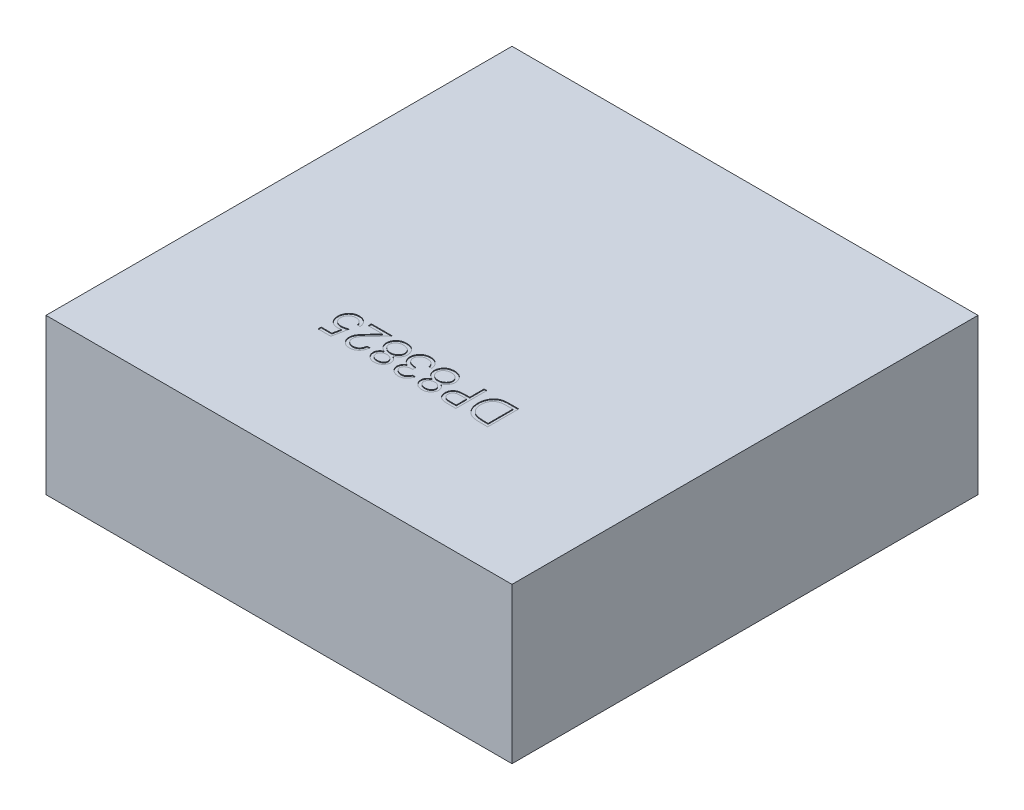
from build123d import *

# Parameters (mm, degrees)
BASES_W          = 3
BASES_H          = 3
BASE_DEPTH       = 1
PARTNUMBER_DEPTH = 0.005


with BuildPart() as part:
    # BaseS → Base (new body)
    with BuildSketch(Plane(origin=(0, 0, 0), x_dir=(1, 0, 0), z_dir=(0, 1, 0))):
        Rectangle(BASES_W, BASES_H)
    extrude(amount=BASE_DEPTH)

    # PartNumberS → PartNumber (cut)
    with BuildSketch(Plane(origin=(0, 1, 0), x_dir=(1, 0, 0), z_dir=(0, 1, 0))):
        with BuildLine():
            Line((0.543589744, -0.5), (0.543589744, -0.7))
            Line((0.543589744, -0.7), (0.503205128, -0.7))
            add(Edge.make_bspline(
                [(0.503205128, -0.7), (0.499692607, -0.699974779), (0.492906435, -0.699926053), (0.483100107, -0.699615336), (0.474039691, -0.699071227), (0.46573033, -0.698263381), (0.458158677, -0.697293739), (0.451336857, -0.696060596), (0.445253815, -0.694610337), (0.441512712, -0.693373396), (0.43974359, -0.692788462)],
                knots=[0, 0, 0, 0, 1.314317071, 2.539253741, 3.67075822, 4.709970291, 5.662644612, 6.526156501, 7.303037452, 8, 8, 8, 8], degree=3))
            add(Edge.make_bspline(
                [(0.43974359, -0.692788462), (0.437429398, -0.691906981), (0.432853492, -0.690164008), (0.426341803, -0.686871104), (0.420190986, -0.683155356), (0.414449607, -0.678931575), (0.409105016, -0.674253735), (0.404089966, -0.669159683), (0.399548204, -0.663513427), (0.395323083, -0.657490166), (0.391625007, -0.651035088), (0.388364014, -0.644277488), (0.385579621, -0.637230477), (0.383407047, -0.629842637), (0.381612125, -0.622184924), (0.380407776, -0.614199361), (0.379607776, -0.605932503), (0.379527773, -0.600322461), (0.379487179, -0.597475962)],
                knots=[0, 0, 0, 0, 0.984696416, 1.947063185, 2.89840987, 3.841051395, 4.778753227, 5.721858861, 6.681155121, 7.65838316, 8.646299769, 9.637283673, 10.641736726, 11.657050558, 12.698485921, 13.768600492, 14.86780186, 16, 16, 16, 16], degree=3))
            add(Edge.make_bspline(
                [(0.379487179, -0.597475962), (0.379523145, -0.595003899), (0.379594018, -0.590132442), (0.380229632, -0.582952842), (0.381155261, -0.575986791), (0.382581759, -0.569264875), (0.384334606, -0.562741838), (0.386498066, -0.556448566), (0.389062316, -0.550380781), (0.392036117, -0.544586677), (0.395292309, -0.539080345), (0.398840463, -0.533949028), (0.402559095, -0.529136152), (0.40658383, -0.524750444), (0.410781412, -0.520655332), (0.415294606, -0.517032476), (0.419982101, -0.513713686), (0.424984721, -0.510799747), (0.430343511, -0.508207712), (0.436198451, -0.506018723), (0.442528171, -0.504134935), (0.449374613, -0.502634061), (0.456714945, -0.501424281), (0.464569063, -0.500618629), (0.472922261, -0.500072297), (0.478658238, -0.500024567), (0.481610577, -0.5)],
                knots=[0, 0, 0, 0, 1.105894396, 2.179280415, 3.222964075, 4.248423888, 5.251546139, 6.243661943, 7.223682738, 8.196462441, 9.155694589, 10.083899862, 10.986397372, 11.874737962, 12.745335529, 13.607670254, 14.461432187, 15.313100333, 16.195087267, 17.121790994, 18.106827133, 19.14775296, 20.255889161, 21.433815148, 22.679170477, 24, 24, 24, 24], degree=3))
            Line((0.481610577, -0.5), (0.543589744, -0.5))
        make_face()
        with BuildLine():
            Line((0.525641026, -0.520512821), (0.502684295, -0.520512821))
            add(Edge.make_bspline(
                [(0.502684295, -0.520512821), (0.499385531, -0.520526997), (0.493040799, -0.520554265), (0.483917485, -0.520793534), (0.47558152, -0.521184501), (0.468031719, -0.521731649), (0.461272346, -0.52245557), (0.455289275, -0.523262707), (0.450102117, -0.524268276), (0.446963292, -0.525179759), (0.445512821, -0.525600962)],
                knots=[0, 0, 0, 0, 1.375205317, 2.645023457, 3.804390687, 4.853969522, 5.800190428, 6.637939096, 7.370582563, 8, 8, 8, 8], degree=3))
            add(Edge.make_bspline(
                [(0.445512821, -0.525600962), (0.443687161, -0.52624386), (0.440079448, -0.5275143), (0.434886804, -0.529832576), (0.430041477, -0.532575274), (0.42546269, -0.535641994), (0.42117987, -0.539080089), (0.41721285, -0.542900492), (0.413530295, -0.547058974), (0.410191167, -0.551569547), (0.407171191, -0.556382165), (0.404561941, -0.561491465), (0.402362373, -0.566868777), (0.400557774, -0.572495393), (0.399150806, -0.57837466), (0.398160244, -0.584521333), (0.397546405, -0.590932984), (0.397473135, -0.595297753), (0.397435897, -0.597516026)],
                knots=[0, 0, 0, 0, 0.998420628, 1.972994, 2.929372424, 3.86770908, 4.81360496, 5.759023883, 6.706048443, 7.676227424, 8.651287839, 9.634325482, 10.632389399, 11.645655052, 12.680158286, 13.74837235, 14.855672678, 16, 16, 16, 16], degree=3))
            add(Edge.make_bspline(
                [(0.397435897, -0.597516026), (0.397465259, -0.599855068), (0.397522941, -0.604450136), (0.398246744, -0.61119266), (0.399306725, -0.61767655), (0.400831424, -0.623906472), (0.402801204, -0.629874323), (0.405158205, -0.635613817), (0.408019974, -0.641051094), (0.4112598, -0.646232204), (0.414897097, -0.651078684), (0.418915732, -0.655533753), (0.423273329, -0.659605711), (0.427949807, -0.663301041), (0.43301055, -0.666554027), (0.438369921, -0.669447832), (0.444103412, -0.671906581), (0.448092784, -0.673213849), (0.450120192, -0.673878205)],
                knots=[0, 0, 0, 0, 1.122272916, 2.204715076, 3.251197285, 4.274229216, 5.279697671, 6.265416158, 7.248880903, 8.225321784, 9.195852973, 10.153576302, 11.101466393, 12.055578741, 13.010401466, 13.985536859, 14.976245305, 16, 16, 16, 16], degree=3))
            add(Edge.make_bspline(
                [(0.450120192, -0.673878205), (0.451797401, -0.674342001), (0.455363606, -0.675328158), (0.461183004, -0.676403894), (0.467732441, -0.677352722), (0.475040995, -0.678156039), (0.483100336, -0.678732457), (0.491916661, -0.679165104), (0.501493781, -0.679456911), (0.508132783, -0.679476838), (0.511578526, -0.679487179)],
                knots=[0, 0, 0, 0, 0.674548936, 1.434276114, 2.292660221, 3.240891867, 4.284742987, 5.42552168, 6.663806718, 8, 8, 8, 8], degree=3))
            Line((0.511578526, -0.679487179), (0.525641026, -0.679487179))
            Line((0.525641026, -0.679487179), (0.525641026, -0.520512821))
        make_face(mode=Mode.SUBTRACT)
        with BuildLine():
            Line((0.338461538, -0.7), (0.299238782, -0.7))
            add(Edge.make_bspline(
                [(0.299238782, -0.7), (0.296541016, -0.699997035), (0.291371976, -0.699991352), (0.283959687, -0.699819081), (0.277227703, -0.699588985), (0.271190538, -0.699270019), (0.265829618, -0.698893071), (0.261169201, -0.698364383), (0.257172655, -0.697812366), (0.254778001, -0.697251143), (0.253685897, -0.696995192)],
                knots=[0, 0, 0, 0, 1.415646017, 2.712440637, 3.8905458, 4.950247383, 5.884950622, 6.709939814, 7.411656543, 8, 8, 8, 8], degree=3))
            add(Edge.make_bspline(
                [(0.253685897, -0.696995192), (0.252303419, -0.696616784), (0.249571037, -0.695868883), (0.245633708, -0.694371122), (0.241888245, -0.692594385), (0.238318984, -0.690572427), (0.234987068, -0.688209761), (0.231788469, -0.685642753), (0.228790266, -0.682767587), (0.226037732, -0.679588048), (0.22348739, -0.676208296), (0.221352571, -0.67254215), (0.219467441, -0.66871679), (0.217998343, -0.664638818), (0.216843575, -0.660362064), (0.216002557, -0.655875395), (0.215462016, -0.651188492), (0.215410725, -0.64798496), (0.215384615, -0.646354167)],
                knots=[0, 0, 0, 0, 0.999333726, 1.975119402, 2.933498163, 3.889020618, 4.832249799, 5.779334906, 6.747801194, 7.724875447, 8.710438469, 9.696133548, 10.679360639, 11.681339199, 12.714023775, 13.766351759, 14.862936069, 16, 16, 16, 16], degree=3))
            add(Edge.make_bspline(
                [(0.215384615, -0.646354167), (0.215408697, -0.644709722), (0.215455814, -0.641492256), (0.216021316, -0.636785239), (0.216783041, -0.632287046), (0.217954301, -0.628007648), (0.21948834, -0.623972462), (0.221287885, -0.62011982), (0.223458373, -0.616515267), (0.225952363, -0.613145717), (0.22872674, -0.610008008), (0.231769765, -0.607124877), (0.235069153, -0.604513201), (0.238614419, -0.602167124), (0.242440124, -0.600141051), (0.246488247, -0.598326348), (0.250793974, -0.596802287), (0.253773546, -0.596000569), (0.255288462, -0.595592949)],
                knots=[0, 0, 0, 0, 1.121902311, 2.195077645, 3.232258892, 4.234102512, 5.217864754, 6.176164875, 7.132989551, 8.084763148, 9.034132444, 9.988522005, 10.94243251, 11.903244335, 12.886203696, 13.894208494, 14.929344452, 16, 16, 16, 16], degree=3))
            add(Edge.make_bspline(
                [(0.255288462, -0.595592949), (0.256541466, -0.595326691), (0.259287499, -0.594743172), (0.263809657, -0.594087314), (0.269077464, -0.593549438), (0.275072997, -0.593047488), (0.281810237, -0.592781517), (0.289273732, -0.592469224), (0.297488742, -0.59232187), (0.303218455, -0.592312555), (0.306209936, -0.592307692)],
                knots=[0, 0, 0, 0, 0.601372724, 1.317943291, 2.144091499, 3.08771165, 4.142394186, 5.309582461, 6.595334295, 8, 8, 8, 8], degree=3))
            Line((0.306209936, -0.592307692), (0.320512821, -0.592307692))
            Line((0.320512821, -0.592307692), (0.320512821, -0.5))
            Line((0.320512821, -0.5), (0.338461538, -0.5))
            Line((0.338461538, -0.5), (0.338461538, -0.7))
        make_face()
        with BuildLine():
            Line((0.320512821, -0.679487179), (0.320512821, -0.612820513))
            Line((0.320512821, -0.612820513), (0.285496795, -0.612379808))
            add(Edge.make_bspline(
                [(0.285496795, -0.612379808), (0.283787056, -0.61237868), (0.28048644, -0.612376504), (0.275705726, -0.612608136), (0.271281004, -0.612860126), (0.267205742, -0.613267653), (0.26349854, -0.613764708), (0.260150423, -0.614429274), (0.25713467, -0.615107089), (0.253660857, -0.616283217), (0.249769822, -0.618057557), (0.245546671, -0.620707753), (0.241938335, -0.624046335), (0.238842209, -0.627840667), (0.236394934, -0.632066148), (0.234621287, -0.636574615), (0.233538689, -0.641348947), (0.233402616, -0.644612418), (0.233333333, -0.646274038)],
                knots=[0, 0, 0, 0, 1.160501667, 2.240324542, 3.248665471, 4.168823117, 5.020172044, 5.786515869, 6.485785279, 7.116517804, 8.272762037, 9.381837012, 10.485674779, 11.594342068, 12.695271952, 13.786226926, 14.872841088, 16, 16, 16, 16], degree=3))
            add(Edge.make_bspline(
                [(0.233333333, -0.646274038), (0.233405707, -0.647881827), (0.233549577, -0.651077912), (0.234612344, -0.655764279), (0.236413717, -0.660221491), (0.238844205, -0.664413482), (0.241866136, -0.668197729), (0.24540271, -0.671461906), (0.249398902, -0.674103874), (0.253087222, -0.675862608), (0.256387977, -0.676893968), (0.25924118, -0.677638558), (0.262479129, -0.678152086), (0.26607118, -0.678643436), (0.270012736, -0.679040062), (0.274328858, -0.679315492), (0.279005171, -0.679474996), (0.282251474, -0.67948302), (0.283934295, -0.679487179)],
                knots=[0, 0, 0, 0, 1.12039168, 2.227199994, 3.330242575, 4.460839274, 5.593542475, 6.693949254, 7.801736126, 8.92216649, 9.528704869, 10.210659466, 10.975987387, 11.81211542, 12.738540127, 13.736887663, 14.826846554, 16, 16, 16, 16], degree=3))
            Line((0.283934295, -0.679487179), (0.320512821, -0.679487179))
        make_face(mode=Mode.SUBTRACT)
        with BuildLine():
            add(Edge.make_bspline(
                [(0.095072115, -0.611418269), (0.093448086, -0.610564826), (0.09027078, -0.60889512), (0.085744586, -0.606198493), (0.081520102, -0.60345477), (0.077675464, -0.600565302), (0.074172977, -0.597591509), (0.071001864, -0.594541261), (0.068128021, -0.591424203), (0.065650177, -0.588160203), (0.063451692, -0.584807304), (0.061589306, -0.581324182), (0.059963915, -0.577761169), (0.058688187, -0.574064171), (0.057634926, -0.570283906), (0.056910765, -0.566369649), (0.056521184, -0.56234771), (0.056447543, -0.559629518), (0.056410256, -0.558253205)],
                knots=[0, 0, 0, 0, 1.264219729, 2.473363326, 3.62979159, 4.734286947, 5.785533755, 6.79450939, 7.765315851, 8.704182021, 9.615576613, 10.525715488, 11.423813905, 12.311666436, 13.218214638, 14.126256791, 15.051260205, 16, 16, 16, 16], degree=3))
            add(Edge.make_bspline(
                [(0.056410256, -0.558253205), (0.056454091, -0.556327537), (0.056540855, -0.552515919), (0.057304446, -0.546891633), (0.058432371, -0.54140719), (0.060145798, -0.536124764), (0.06225425, -0.530999346), (0.064914839, -0.52609999), (0.067917657, -0.521286058), (0.070332554, -0.518325141), (0.071554487, -0.516826923)],
                knots=[0, 0, 0, 0, 1.02531512, 2.029483338, 3.018748588, 4.004195107, 4.983200899, 5.966616707, 6.971112471, 8, 8, 8, 8], degree=3))
            add(Edge.make_bspline(
                [(0.071554487, -0.516826923), (0.073145143, -0.515078707), (0.076306798, -0.511603879), (0.081722965, -0.507092404), (0.087667073, -0.50330101), (0.094116121, -0.500211188), (0.101052869, -0.497806282), (0.108475841, -0.496078138), (0.116399507, -0.495088285), (0.121845534, -0.4949452), (0.124639423, -0.494871795)],
                knots=[0, 0, 0, 0, 0.954267603, 1.896743057, 2.838368354, 3.796610408, 4.779680527, 5.799409237, 6.871065594, 8, 8, 8, 8], degree=3))
            add(Edge.make_bspline(
                [(0.124639423, -0.494871795), (0.127325841, -0.494937827), (0.132553336, -0.49506632), (0.140163209, -0.49593214), (0.147265419, -0.497464973), (0.153893637, -0.499519585), (0.159983771, -0.502259459), (0.165546895, -0.505617745), (0.170664546, -0.509518623), (0.175176177, -0.514055973), (0.179180498, -0.518916859), (0.182701081, -0.523930136), (0.185610833, -0.529092156), (0.188118805, -0.534324398), (0.189985223, -0.539732879), (0.19130901, -0.545262095), (0.192140532, -0.550896339), (0.192251744, -0.554698039), (0.192307692, -0.556610577)],
                knots=[0, 0, 0, 0, 1.256864279, 2.445730223, 3.576845088, 4.651810441, 5.686528262, 6.692706664, 7.686234615, 8.689148594, 9.678739427, 10.630299996, 11.55097961, 12.448208961, 13.341360817, 14.221834469, 15.105450545, 16, 16, 16, 16], degree=3))
            add(Edge.make_bspline(
                [(0.192307692, -0.556610577), (0.192274662, -0.558013956), (0.192209384, -0.560787529), (0.191757795, -0.56488525), (0.191031164, -0.568873432), (0.190046512, -0.572767815), (0.188699829, -0.57654785), (0.187102182, -0.580233033), (0.185221368, -0.583823256), (0.182983326, -0.587263859), (0.180517583, -0.590676716), (0.177590521, -0.593892364), (0.174397283, -0.597099685), (0.170747775, -0.600103642), (0.166839098, -0.603152404), (0.162488961, -0.605991149), (0.157842414, -0.608841427), (0.15453909, -0.610544584), (0.152844551, -0.611418269)],
                knots=[0, 0, 0, 0, 0.941575622, 1.860885767, 2.762557628, 3.660168386, 4.552890429, 5.45184204, 6.353736508, 7.268493418, 8.204037487, 9.175167802, 10.182660057, 11.238220596, 12.344046335, 13.507168087, 14.721227736, 16, 16, 16, 16], degree=3))
            add(Edge.make_bspline(
                [(0.152844551, -0.611418269), (0.155161235, -0.612686787), (0.159639967, -0.615139152), (0.165626949, -0.619588623), (0.170698429, -0.624494994), (0.174800511, -0.629865647), (0.178039312, -0.635524067), (0.180329181, -0.641440467), (0.181823831, -0.647548858), (0.181975241, -0.651714174), (0.182051282, -0.65380609)],
                knots=[0, 0, 0, 0, 1.16701039, 2.256125286, 3.287752239, 4.277689688, 5.235169525, 6.160862735, 7.076343936, 8, 8, 8, 8], degree=3))
            add(Edge.make_bspline(
                [(0.182051282, -0.65380609), (0.181957663, -0.65593728), (0.181769474, -0.660221345), (0.180252979, -0.666600352), (0.177762975, -0.672868993), (0.17443421, -0.679012741), (0.170197946, -0.68475165), (0.165183735, -0.68994045), (0.159397884, -0.694444849), (0.152967566, -0.698252547), (0.146060008, -0.701366404), (0.138759626, -0.703492187), (0.131196531, -0.704890317), (0.126047994, -0.705048169), (0.1234375, -0.705128205)],
                knots=[0, 0, 0, 0, 0.888724595, 1.786491426, 2.720083884, 3.697804067, 4.69440576, 5.687697823, 6.7000873, 7.744853364, 8.800284131, 9.853047784, 10.91141782, 12, 12, 12, 12], degree=3))
            add(Edge.make_bspline(
                [(0.1234375, -0.705128205), (0.12089433, -0.705045914), (0.115879488, -0.704883645), (0.108497178, -0.703516914), (0.101427646, -0.701259841), (0.094710514, -0.698185699), (0.088488708, -0.694355228), (0.082951877, -0.689801259), (0.078054821, -0.684668997), (0.074008968, -0.67891116), (0.07076334, -0.672767821), (0.068426113, -0.666395151), (0.0669485, -0.659869548), (0.066760739, -0.65545632), (0.066666667, -0.653245192)],
                knots=[0, 0, 0, 0, 1.072634126, 2.115112298, 3.156050586, 4.19761425, 5.225177188, 6.230426315, 7.215180151, 8.209739481, 9.190420596, 10.139012357, 11.067603024, 12, 12, 12, 12], degree=3))
            add(Edge.make_bspline(
                [(0.066666667, -0.653245192), (0.066749137, -0.651075288), (0.066911105, -0.646813718), (0.068255664, -0.640610289), (0.070555277, -0.63481268), (0.073657461, -0.629331678), (0.077729149, -0.62425487), (0.082688129, -0.619557042), (0.088470053, -0.615146315), (0.092822236, -0.612688729), (0.095072115, -0.611418269)],
                knots=[0, 0, 0, 0, 0.975463758, 1.915755378, 2.838359076, 3.772025586, 4.738400888, 5.753889765, 6.838863581, 8, 8, 8, 8], degree=3))
        make_face()
        with BuildLine():
            add(Edge.make_bspline(
                [(0.124439103, -0.684615385), (0.125842055, -0.68457828), (0.128586843, -0.684505687), (0.132610652, -0.684123506), (0.136440115, -0.683389395), (0.140096173, -0.682383673), (0.143591352, -0.681132354), (0.146845499, -0.679483698), (0.149967974, -0.67765121), (0.152856339, -0.675501785), (0.155471044, -0.673156716), (0.157806436, -0.670707661), (0.159709055, -0.668082423), (0.161345949, -0.665412338), (0.162561571, -0.662586659), (0.163425107, -0.659667255), (0.164036238, -0.656635634), (0.164080284, -0.654570362), (0.164102564, -0.653525641)],
                knots=[0, 0, 0, 0, 1.20353747, 2.354645537, 3.462130888, 4.543058862, 5.604822423, 6.639552563, 7.666902586, 8.706944258, 9.720926464, 10.677177239, 11.602682187, 12.496457588, 13.358248655, 14.231532794, 15.105417644, 16, 16, 16, 16], degree=3))
            add(Edge.make_bspline(
                [(0.164102564, -0.653525641), (0.16406193, -0.652481511), (0.16398163, -0.65041816), (0.163400418, -0.647358955), (0.162428627, -0.644391821), (0.161096092, -0.641489058), (0.159386034, -0.638658118), (0.157310533, -0.635888153), (0.154779535, -0.633252413), (0.15198455, -0.630676115), (0.148931523, -0.628302534), (0.145723347, -0.626182322), (0.142336608, -0.624492107), (0.138872732, -0.623010134), (0.135258466, -0.621898483), (0.13151873, -0.621097603), (0.127657519, -0.620602209), (0.125041531, -0.620542853), (0.123717949, -0.620512821)],
                knots=[0, 0, 0, 0, 0.873213166, 1.72559466, 2.594724523, 3.479581045, 4.391597569, 5.35687048, 6.368548091, 7.443976143, 8.534559525, 9.600545123, 10.654815915, 11.696401765, 12.749428718, 13.812189468, 14.893058657, 16, 16, 16, 16], degree=3))
            add(Edge.make_bspline(
                [(0.123717949, -0.620512821), (0.122017841, -0.620562447), (0.118634417, -0.62066121), (0.113648532, -0.621587854), (0.108788446, -0.623027019), (0.10414612, -0.625069654), (0.099804641, -0.627560117), (0.095886456, -0.630497069), (0.092555535, -0.633949484), (0.089721768, -0.637717094), (0.087506164, -0.641713618), (0.085808977, -0.645740643), (0.084809483, -0.649831338), (0.084679557, -0.652572418), (0.084615385, -0.653926282)],
                knots=[0, 0, 0, 0, 1.076561449, 2.142489767, 3.202892658, 4.283174188, 5.348766409, 6.369549039, 7.375093932, 8.378927502, 9.349008457, 10.26378795, 11.142457041, 12, 12, 12, 12], degree=3))
            add(Edge.make_bspline(
                [(0.084615385, -0.653926282), (0.084645217, -0.654876655), (0.084704429, -0.656763008), (0.085212138, -0.659557766), (0.086004009, -0.662290685), (0.087158273, -0.664945724), (0.088554573, -0.667584561), (0.090334402, -0.670124414), (0.092397123, -0.672642144), (0.094772513, -0.675054881), (0.097456214, -0.677320023), (0.100469934, -0.679283546), (0.10378708, -0.680920906), (0.107363178, -0.682296491), (0.111236022, -0.683318149), (0.115372266, -0.684086984), (0.119809232, -0.684519435), (0.12286234, -0.684582708), (0.124439103, -0.684615385)],
                knots=[0, 0, 0, 0, 0.814035228, 1.61574325, 2.427118093, 3.24780647, 4.092880925, 4.981933388, 5.900917883, 6.880367106, 7.87994501, 8.905470125, 9.95492938, 11.0455354, 12.184050453, 13.382997595, 14.64846247, 16, 16, 16, 16], degree=3))
        make_face(mode=Mode.SUBTRACT)
        with BuildLine():
            add(Edge.make_bspline(
                [(0.123277244, -0.6), (0.125055855, -0.599968354), (0.128545057, -0.599906273), (0.13365695, -0.599215573), (0.138562594, -0.598253427), (0.143246929, -0.596796207), (0.147685909, -0.594900166), (0.151942005, -0.592651786), (0.155948568, -0.58995688), (0.159687689, -0.586880797), (0.163110956, -0.58354732), (0.166125189, -0.580026723), (0.168671789, -0.576366811), (0.170738384, -0.572562955), (0.172341593, -0.568623537), (0.173524787, -0.564546257), (0.174211747, -0.560319741), (0.174309625, -0.557454335), (0.174358974, -0.556009615)],
                knots=[0, 0, 0, 0, 1.140332253, 2.237053636, 3.304055028, 4.344690294, 5.377465719, 6.397042765, 7.428360044, 8.469453732, 9.499453352, 10.490108612, 11.438398528, 12.354680514, 13.261581007, 14.161901135, 15.073242693, 16, 16, 16, 16], degree=3))
            add(Edge.make_bspline(
                [(0.174358974, -0.556009615), (0.174279634, -0.554213877), (0.174121649, -0.550638134), (0.17291325, -0.545366854), (0.17092871, -0.540265191), (0.168144634, -0.535405096), (0.164748712, -0.530845496), (0.160620307, -0.526815098), (0.155860072, -0.523368157), (0.150507117, -0.520487221), (0.14463923, -0.518205481), (0.138292673, -0.516573052), (0.131510437, -0.515547001), (0.12683336, -0.515439597), (0.124439103, -0.515384615)],
                knots=[0, 0, 0, 0, 0.899105568, 1.790333855, 2.694925079, 3.632758987, 4.588257081, 5.534574046, 6.511571685, 7.523527334, 8.572244311, 9.657983075, 10.801090915, 12, 12, 12, 12], degree=3))
            add(Edge.make_bspline(
                [(0.124439103, -0.515384615), (0.122567783, -0.515420967), (0.118921852, -0.515491791), (0.113600858, -0.51610394), (0.108591274, -0.51710387), (0.103845107, -0.518459669), (0.099397684, -0.520256898), (0.095255066, -0.52248923), (0.091360842, -0.525039034), (0.087881445, -0.528057783), (0.084717817, -0.531288031), (0.081946728, -0.534689588), (0.079601535, -0.538228389), (0.077711084, -0.541902361), (0.076209885, -0.545698003), (0.075127692, -0.549630896), (0.074460706, -0.553716489), (0.074393195, -0.556487844), (0.074358974, -0.557892628)],
                knots=[0, 0, 0, 0, 1.224631902, 2.385975653, 3.500340538, 4.565441647, 5.612488581, 6.63322211, 7.641830068, 8.652595074, 9.641693811, 10.598750962, 11.520088299, 12.415429315, 13.298523938, 14.187139574, 15.081071174, 16, 16, 16, 16], degree=3))
            add(Edge.make_bspline(
                [(0.074358974, -0.557892628), (0.074410395, -0.559257203), (0.074511788, -0.561947906), (0.075164559, -0.565932312), (0.07628515, -0.569797522), (0.077919162, -0.573526106), (0.079925811, -0.577161434), (0.082404663, -0.580672989), (0.085325505, -0.584070494), (0.088681189, -0.587283997), (0.092317992, -0.590254735), (0.09617221, -0.592894765), (0.100261406, -0.595052486), (0.104504576, -0.596865123), (0.108944495, -0.598277723), (0.113559747, -0.599268256), (0.118359076, -0.599890806), (0.121619333, -0.599963191), (0.123277244, -0.6)],
                knots=[0, 0, 0, 0, 0.917336384, 1.808827106, 2.706624561, 3.615530867, 4.539869921, 5.493819324, 6.499753197, 7.547410123, 8.613069608, 9.653934021, 10.682176708, 11.716048074, 12.752411263, 13.808993382, 14.885826486, 16, 16, 16, 16], degree=3))
        make_face(mode=Mode.SUBTRACT)
        with BuildLine():
            Line((0.012820513, -0.653846154), (0.030769231, -0.653846154))
            add(Edge.make_bspline(
                [(0.030769231, -0.653846154), (0.030282971, -0.655859439), (0.029332372, -0.659795246), (0.027349654, -0.665418518), (0.025189696, -0.670739862), (0.022596033, -0.675659638), (0.019766961, -0.680276718), (0.016525663, -0.684486382), (0.013021679, -0.688395694), (0.009145968, -0.691865022), (0.005081473, -0.695006607), (0.000770923, -0.697685181), (-0.003698957, -0.699989419), (-0.008359136, -0.701887718), (-0.013223488, -0.703317748), (-0.018248038, -0.704355279), (-0.023445953, -0.705029057), (-0.026974386, -0.705094815), (-0.028766026, -0.705128205)],
                knots=[0, 0, 0, 0, 1.162005537, 2.271625781, 3.343758855, 4.383309926, 5.390229558, 6.379919256, 7.361854164, 8.333198761, 9.295911338, 10.242430842, 11.177959212, 12.116337295, 13.062827104, 14.020064771, 14.994644689, 16, 16, 16, 16], degree=3))
            add(Edge.make_bspline(
                [(-0.028766026, -0.705128205), (-0.031376468, -0.705049392), (-0.036540412, -0.704893485), (-0.044126871, -0.703469803), (-0.05144269, -0.701216938), (-0.058407789, -0.698104154), (-0.064877414, -0.694264879), (-0.070633768, -0.689695465), (-0.075598825, -0.684484076), (-0.079764218, -0.67872793), (-0.083025647, -0.672576186), (-0.085430583, -0.666244749), (-0.086894679, -0.659748636), (-0.087084425, -0.655362506), (-0.087179487, -0.653165064)],
                knots=[0, 0, 0, 0, 1.083050992, 2.142477498, 3.193116406, 4.255571735, 5.30263384, 6.308962982, 7.297363603, 8.282367274, 9.249857812, 10.179914175, 11.08814088, 12, 12, 12, 12], degree=3))
            add(Edge.make_bspline(
                [(-0.087179487, -0.653165064), (-0.087112996, -0.65105039), (-0.086982884, -0.646912301), (-0.085878101, -0.640871073), (-0.084018886, -0.635177267), (-0.081443471, -0.629806915), (-0.078109668, -0.624794067), (-0.074071228, -0.620127445), (-0.069299647, -0.61578635), (-0.065683708, -0.613299523), (-0.063822115, -0.612019231)],
                knots=[0, 0, 0, 0, 1.024540389, 2.004866551, 2.965041327, 3.920577974, 4.882998113, 5.874504559, 6.905732034, 8, 8, 8, 8], degree=3))
            add(Edge.make_bspline(
                [(-0.063822115, -0.612019231), (-0.065952356, -0.610995631), (-0.070179819, -0.608964297), (-0.0758839, -0.604917242), (-0.081140957, -0.600359254), (-0.084038259, -0.596762548), (-0.085496795, -0.594951923)],
                knots=[0, 0, 0, 0, 1.015663554, 2.015584519, 3.001021554, 4, 4, 4, 4], degree=3))
            add(Edge.make_bspline(
                [(-0.085496795, -0.594951923), (-0.086459549, -0.593634478), (-0.088369292, -0.591021161), (-0.090719885, -0.586817028), (-0.092876712, -0.582580215), (-0.094464075, -0.578144135), (-0.095833906, -0.573651284), (-0.09673521, -0.569005451), (-0.09731381, -0.564250776), (-0.097395058, -0.561032679), (-0.097435897, -0.559415064)],
                knots=[0, 0, 0, 0, 1.02516404, 2.033540309, 3.025129118, 4.011046665, 4.991655828, 5.976607087, 6.982917762, 8, 8, 8, 8], degree=3))
            add(Edge.make_bspline(
                [(-0.097435897, -0.559415064), (-0.097333113, -0.556614634), (-0.097128029, -0.551026954), (-0.095302832, -0.54276937), (-0.092455757, -0.534712452), (-0.088487886, -0.526970463), (-0.083556422, -0.519748905), (-0.07772183, -0.513268976), (-0.070977897, -0.507749819), (-0.063520977, -0.503097513), (-0.055410893, -0.499410613), (-0.046770987, -0.496753903), (-0.037652414, -0.49516025), (-0.031416635, -0.494969041), (-0.028245192, -0.494871795)],
                knots=[0, 0, 0, 0, 0.955619592, 1.906742024, 2.874954321, 3.868585453, 4.869520953, 5.854611167, 6.836527075, 7.836578462, 8.849204403, 9.870874567, 10.917152508, 12, 12, 12, 12], degree=3))
            add(Edge.make_bspline(
                [(-0.028245192, -0.494871795), (-0.026107081, -0.49492184), (-0.021899991, -0.495020311), (-0.015712732, -0.495681497), (-0.009819218, -0.496921931), (-0.004162223, -0.498481947), (0.001172877, -0.500638844), (0.006262821, -0.503210266), (0.0110853, -0.506262151), (0.015611673, -0.509799634), (0.019837104, -0.513759317), (0.023653945, -0.518206982), (0.027104423, -0.523059619), (0.030166616, -0.52836088), (0.03285341, -0.534095915), (0.035106986, -0.540287707), (0.037074636, -0.546888254), (0.037991249, -0.551486777), (0.038461538, -0.553846154)],
                knots=[0, 0, 0, 0, 1.048603596, 2.063302207, 3.045874044, 3.999447474, 4.937100059, 5.862643889, 6.7929026, 7.7308982, 8.676022965, 9.627908155, 10.600123445, 11.591992905, 12.626222643, 13.701663232, 14.820785756, 16, 16, 16, 16], degree=3))
            Line((0.038461538, -0.553846154), (0.020512821, -0.553846154))
            add(Edge.make_bspline(
                [(0.020512821, -0.553846154), (0.020045204, -0.55230621), (0.019135649, -0.549310886), (0.017587403, -0.545000012), (0.015823502, -0.541048123), (0.013931241, -0.53742623), (0.011943902, -0.534098664), (0.009720192, -0.531153415), (0.007424812, -0.528461117), (0.005694563, -0.526944282), (0.004847756, -0.526201923)],
                knots=[0, 0, 0, 0, 1.198163088, 2.33053128, 3.407730985, 4.417276592, 5.372219308, 6.28897303, 7.162600585, 8, 8, 8, 8], degree=3))
            add(Edge.make_bspline(
                [(0.004847756, -0.526201923), (0.003727827, -0.525338946), (0.001491425, -0.523615655), (-0.002150597, -0.521410219), (-0.005994289, -0.519522419), (-0.010071706, -0.517987935), (-0.014383394, -0.516836097), (-0.018911864, -0.516007058), (-0.023664545, -0.515459763), (-0.026908156, -0.51541003), (-0.028565705, -0.515384615)],
                knots=[0, 0, 0, 0, 0.946083416, 1.889246487, 2.84504177, 3.809995578, 4.801312957, 5.829064617, 6.89060985, 8, 8, 8, 8], degree=3))
            add(Edge.make_bspline(
                [(-0.028565705, -0.515384615), (-0.030437359, -0.515419753), (-0.034097217, -0.515488461), (-0.039437141, -0.516122158), (-0.044518831, -0.517041039), (-0.049290429, -0.518478347), (-0.053816865, -0.520202635), (-0.057997096, -0.522460045), (-0.061954014, -0.525009425), (-0.065571702, -0.527974844), (-0.068833224, -0.531180141), (-0.071651539, -0.534580675), (-0.074092522, -0.538071008), (-0.076054666, -0.541732562), (-0.077606813, -0.545529421), (-0.078662813, -0.549475795), (-0.079397234, -0.553538455), (-0.079457034, -0.556300116), (-0.079487179, -0.557692308)],
                knots=[0, 0, 0, 0, 1.216990249, 2.379719373, 3.493992396, 4.571561497, 5.616923107, 6.638958652, 7.655775068, 8.674704564, 9.676001865, 10.625896028, 11.54399481, 12.441854662, 13.322657739, 14.20572845, 15.095482574, 16, 16, 16, 16], degree=3))
            add(Edge.make_bspline(
                [(-0.079487179, -0.557692308), (-0.079399551, -0.559555696), (-0.079224731, -0.5632732), (-0.077895545, -0.568744529), (-0.075689671, -0.574018171), (-0.072661586, -0.579025064), (-0.068887132, -0.583611196), (-0.064544725, -0.58771628), (-0.059541713, -0.591134393), (-0.054910874, -0.593489428), (-0.050798365, -0.595058495), (-0.047286074, -0.596158774), (-0.043350443, -0.597038296), (-0.03903876, -0.597889066), (-0.034332829, -0.598602295), (-0.029228414, -0.599199653), (-0.02372346, -0.599676883), (-0.019912544, -0.599890117), (-0.017948718, -0.6)],
                knots=[0, 0, 0, 0, 1.070440979, 2.135555593, 3.216243406, 4.345886539, 5.486149072, 6.621334998, 7.769144672, 8.957074012, 9.598644492, 10.297969361, 11.070758978, 11.915404831, 12.824182859, 13.805940418, 14.869366021, 16, 16, 16, 16], degree=3))
            Line((-0.017948718, -0.6), (-0.017948718, -0.620512821))
            add(Edge.make_bspline(
                [(-0.017948718, -0.620512821), (-0.020422108, -0.620561043), (-0.025265177, -0.620655467), (-0.03235955, -0.62156233), (-0.039122704, -0.623034295), (-0.045452911, -0.625089351), (-0.051192825, -0.627591218), (-0.056220175, -0.630392354), (-0.060354102, -0.633623909), (-0.063668643, -0.637133123), (-0.066127074, -0.640920736), (-0.067941743, -0.644850479), (-0.069015081, -0.648995461), (-0.06915862, -0.651823627), (-0.069230769, -0.653245192)],
                knots=[0, 0, 0, 0, 1.321816535, 2.58820849, 3.816448615, 5.017641336, 6.139869627, 7.160068286, 8.085608132, 8.934319198, 9.728416342, 10.48890201, 11.240453369, 12, 12, 12, 12], degree=3))
            add(Edge.make_bspline(
                [(-0.069230769, -0.653245192), (-0.06920761, -0.654289811), (-0.069161535, -0.656368031), (-0.068557263, -0.659413745), (-0.067691186, -0.662366392), (-0.066432952, -0.665191473), (-0.064805673, -0.667897968), (-0.062836907, -0.670495763), (-0.060521668, -0.673009663), (-0.05787499, -0.675384225), (-0.05492123, -0.677521373), (-0.051778939, -0.679426611), (-0.048435869, -0.681028645), (-0.044913803, -0.682356622), (-0.041193704, -0.683353822), (-0.037295143, -0.684070288), (-0.033210105, -0.684518117), (-0.030423153, -0.684582603), (-0.02900641, -0.684615385)],
                knots=[0, 0, 0, 0, 0.884246871, 1.759167212, 2.622361933, 3.489113179, 4.372562419, 5.294145153, 6.247651513, 7.265905295, 8.30305477, 9.334068495, 10.37719476, 11.441246459, 12.52060732, 13.637552802, 14.799054011, 16, 16, 16, 16], degree=3))
            add(Edge.make_bspline(
                [(-0.02900641, -0.684615385), (-0.026729097, -0.684536032), (-0.022280974, -0.684381039), (-0.015869742, -0.683018718), (-0.009915786, -0.680860261), (-0.005380072, -0.678253931), (-0.002025058, -0.67569), (0.000418369, -0.67348425), (0.002774082, -0.670983381), (0.004949643, -0.668118798), (0.007075414, -0.664989002), (0.009131098, -0.661576754), (0.011050666, -0.657833407), (0.012219139, -0.655200978), (0.012820513, -0.653846154)],
                knots=[0, 0, 0, 0, 1.4727372, 2.876598283, 4.222346151, 5.558423782, 6.24313385, 6.953189256, 7.68715613, 8.463578749, 9.278833271, 10.135787152, 11.040551781, 12, 12, 12, 12], degree=3))
        make_face()
        with BuildLine():
            add(Edge.make_bspline(
                [(-0.212620192, -0.611418269), (-0.214244221, -0.610564826), (-0.217421528, -0.60889512), (-0.221947722, -0.606198493), (-0.226172205, -0.60345477), (-0.230016844, -0.600565302), (-0.233519331, -0.597591509), (-0.236690444, -0.594541261), (-0.239564287, -0.591424203), (-0.242042131, -0.588160203), (-0.244240616, -0.584807304), (-0.246103002, -0.581324182), (-0.247728392, -0.577761169), (-0.249004121, -0.574064171), (-0.250057382, -0.570283906), (-0.250781543, -0.566369649), (-0.251171124, -0.56234771), (-0.251244765, -0.559629518), (-0.251282051, -0.558253205)],
                knots=[0, 0, 0, 0, 1.264219729, 2.473363326, 3.62979159, 4.734286947, 5.785533755, 6.79450939, 7.765315851, 8.704182021, 9.615576613, 10.525715488, 11.423813905, 12.311666436, 13.218214638, 14.126256791, 15.051260205, 16, 16, 16, 16], degree=3))
            add(Edge.make_bspline(
                [(-0.251282051, -0.558253205), (-0.251238217, -0.556327537), (-0.251151453, -0.552515919), (-0.250387862, -0.546891633), (-0.249259937, -0.54140719), (-0.24754651, -0.536124764), (-0.245438058, -0.530999346), (-0.242777469, -0.52609999), (-0.23977465, -0.521286058), (-0.237359753, -0.518325141), (-0.236137821, -0.516826923)],
                knots=[0, 0, 0, 0, 1.02531512, 2.029483338, 3.018748588, 4.004195107, 4.983200899, 5.966616707, 6.971112471, 8, 8, 8, 8], degree=3))
            add(Edge.make_bspline(
                [(-0.236137821, -0.516826923), (-0.234547165, -0.515078707), (-0.23138551, -0.511603879), (-0.225969342, -0.507092404), (-0.220025235, -0.50330101), (-0.213576187, -0.500211188), (-0.206639438, -0.497806282), (-0.199216467, -0.496078138), (-0.191292801, -0.495088285), (-0.185846774, -0.4949452), (-0.183052885, -0.494871795)],
                knots=[0, 0, 0, 0, 0.954267603, 1.896743057, 2.838368354, 3.796610408, 4.779680527, 5.799409237, 6.871065594, 8, 8, 8, 8], degree=3))
            add(Edge.make_bspline(
                [(-0.183052885, -0.494871795), (-0.180366467, -0.494937827), (-0.175138972, -0.49506632), (-0.167529098, -0.49593214), (-0.160426889, -0.497464973), (-0.153798671, -0.499519585), (-0.147708536, -0.502259459), (-0.142145413, -0.505617745), (-0.137027762, -0.509518623), (-0.132516131, -0.514055973), (-0.12851181, -0.518916859), (-0.124991226, -0.523930136), (-0.122081475, -0.529092156), (-0.119573503, -0.534324398), (-0.117707085, -0.539732879), (-0.116383298, -0.545262095), (-0.115551775, -0.550896339), (-0.115440563, -0.554698039), (-0.115384615, -0.556610577)],
                knots=[0, 0, 0, 0, 1.256864279, 2.445730223, 3.576845088, 4.651810441, 5.686528262, 6.692706664, 7.686234615, 8.689148594, 9.678739427, 10.630299996, 11.55097961, 12.448208961, 13.341360817, 14.221834469, 15.105450545, 16, 16, 16, 16], degree=3))
            add(Edge.make_bspline(
                [(-0.115384615, -0.556610577), (-0.115417645, -0.558013956), (-0.115482924, -0.560787529), (-0.115934513, -0.56488525), (-0.116661144, -0.568873432), (-0.117645796, -0.572767815), (-0.118992479, -0.57654785), (-0.120590126, -0.580233033), (-0.12247094, -0.583823256), (-0.124708982, -0.587263859), (-0.127174724, -0.590676716), (-0.130101787, -0.593892364), (-0.133295025, -0.597099685), (-0.136944533, -0.600103642), (-0.140853209, -0.603152404), (-0.145203347, -0.605991149), (-0.149849894, -0.608841427), (-0.153153218, -0.610544584), (-0.154847756, -0.611418269)],
                knots=[0, 0, 0, 0, 0.941575622, 1.860885767, 2.762557628, 3.660168386, 4.552890429, 5.45184204, 6.353736508, 7.268493418, 8.204037487, 9.175167802, 10.182660057, 11.238220596, 12.344046335, 13.507168087, 14.721227736, 16, 16, 16, 16], degree=3))
            add(Edge.make_bspline(
                [(-0.154847756, -0.611418269), (-0.152531073, -0.612686787), (-0.14805234, -0.615139152), (-0.142065358, -0.619588623), (-0.136993879, -0.624494994), (-0.132891797, -0.629865647), (-0.129652996, -0.635524067), (-0.127363126, -0.641440467), (-0.125868476, -0.647548858), (-0.125717067, -0.651714174), (-0.125641026, -0.65380609)],
                knots=[0, 0, 0, 0, 1.16701039, 2.256125286, 3.287752239, 4.277689688, 5.235169525, 6.160862735, 7.076343936, 8, 8, 8, 8], degree=3))
            add(Edge.make_bspline(
                [(-0.125641026, -0.65380609), (-0.125734644, -0.65593728), (-0.125922834, -0.660221345), (-0.127439328, -0.666600352), (-0.129929333, -0.672868993), (-0.133258097, -0.679012741), (-0.137494362, -0.68475165), (-0.142508573, -0.68994045), (-0.148294424, -0.694444849), (-0.154724742, -0.698252547), (-0.1616323, -0.701366404), (-0.168932682, -0.703492187), (-0.176495776, -0.704890317), (-0.181644314, -0.705048169), (-0.184254808, -0.705128205)],
                knots=[0, 0, 0, 0, 0.888724595, 1.786491426, 2.720083884, 3.697804067, 4.69440576, 5.687697823, 6.7000873, 7.744853364, 8.800284131, 9.853047784, 10.91141782, 12, 12, 12, 12], degree=3))
            add(Edge.make_bspline(
                [(-0.184254808, -0.705128205), (-0.186797978, -0.705045914), (-0.191812819, -0.704883645), (-0.19919513, -0.703516914), (-0.206264662, -0.701259841), (-0.212981794, -0.698185699), (-0.2192036, -0.694355228), (-0.224740431, -0.689801259), (-0.229637487, -0.684668997), (-0.23368334, -0.67891116), (-0.236928968, -0.672767821), (-0.239266194, -0.666395151), (-0.240743808, -0.659869548), (-0.240931569, -0.65545632), (-0.241025641, -0.653245192)],
                knots=[0, 0, 0, 0, 1.072634126, 2.115112298, 3.156050586, 4.19761425, 5.225177188, 6.230426315, 7.215180151, 8.209739481, 9.190420596, 10.139012357, 11.067603024, 12, 12, 12, 12], degree=3))
            add(Edge.make_bspline(
                [(-0.241025641, -0.653245192), (-0.24094317, -0.651075288), (-0.240781202, -0.646813718), (-0.239436644, -0.640610289), (-0.237137031, -0.63481268), (-0.234034847, -0.629331678), (-0.229963159, -0.62425487), (-0.225004178, -0.619557042), (-0.219222254, -0.615146315), (-0.214870072, -0.612688729), (-0.212620192, -0.611418269)],
                knots=[0, 0, 0, 0, 0.975463758, 1.915755378, 2.838359076, 3.772025586, 4.738400888, 5.753889765, 6.838863581, 8, 8, 8, 8], degree=3))
        make_face()
        with BuildLine():
            add(Edge.make_bspline(
                [(-0.183253205, -0.684615385), (-0.181850253, -0.68457828), (-0.179105465, -0.684505687), (-0.175081656, -0.684123506), (-0.171252193, -0.683389395), (-0.167596134, -0.682383673), (-0.164100956, -0.681132354), (-0.160846808, -0.679483698), (-0.157724334, -0.67765121), (-0.154835968, -0.675501785), (-0.152221264, -0.673156716), (-0.149885872, -0.670707661), (-0.147983252, -0.668082423), (-0.146346359, -0.665412338), (-0.145130737, -0.662586659), (-0.144267201, -0.659667255), (-0.14365607, -0.656635634), (-0.143612024, -0.654570362), (-0.143589744, -0.653525641)],
                knots=[0, 0, 0, 0, 1.20353747, 2.354645537, 3.462130888, 4.543058862, 5.604822423, 6.639552563, 7.666902586, 8.706944258, 9.720926464, 10.677177239, 11.602682187, 12.496457588, 13.358248655, 14.231532794, 15.105417644, 16, 16, 16, 16], degree=3))
            add(Edge.make_bspline(
                [(-0.143589744, -0.653525641), (-0.143630378, -0.652481511), (-0.143710678, -0.65041816), (-0.14429189, -0.647358955), (-0.145263681, -0.644391821), (-0.146596215, -0.641489058), (-0.148306274, -0.638658118), (-0.150381775, -0.635888153), (-0.152912772, -0.633252413), (-0.155707758, -0.630676115), (-0.158760785, -0.628302534), (-0.161968961, -0.626182322), (-0.165355699, -0.624492107), (-0.168819575, -0.623010134), (-0.172433842, -0.621898483), (-0.176173578, -0.621097603), (-0.180034788, -0.620602209), (-0.182650777, -0.620542853), (-0.183974359, -0.620512821)],
                knots=[0, 0, 0, 0, 0.873213166, 1.72559466, 2.594724523, 3.479581045, 4.391597569, 5.35687048, 6.368548091, 7.443976143, 8.534559525, 9.600545123, 10.654815915, 11.696401765, 12.749428718, 13.812189468, 14.893058657, 16, 16, 16, 16], degree=3))
            add(Edge.make_bspline(
                [(-0.183974359, -0.620512821), (-0.185674467, -0.620562447), (-0.18905789, -0.62066121), (-0.194043776, -0.621587854), (-0.198903862, -0.623027019), (-0.203546188, -0.625069654), (-0.207887667, -0.627560117), (-0.211805852, -0.630497069), (-0.215136773, -0.633949484), (-0.217970539, -0.637717094), (-0.220186143, -0.641713618), (-0.221883331, -0.645740643), (-0.222882825, -0.649831338), (-0.223012751, -0.652572418), (-0.223076923, -0.653926282)],
                knots=[0, 0, 0, 0, 1.076561449, 2.142489767, 3.202892658, 4.283174188, 5.348766409, 6.369549039, 7.375093932, 8.378927502, 9.349008457, 10.26378795, 11.142457041, 12, 12, 12, 12], degree=3))
            add(Edge.make_bspline(
                [(-0.223076923, -0.653926282), (-0.223047091, -0.654876655), (-0.222987879, -0.656763008), (-0.22248017, -0.659557766), (-0.221688299, -0.662290685), (-0.220534035, -0.664945724), (-0.219137735, -0.667584561), (-0.217357905, -0.670124414), (-0.215295185, -0.672642144), (-0.212919795, -0.675054881), (-0.210236094, -0.677320023), (-0.207222374, -0.679283546), (-0.203905228, -0.680920906), (-0.20032913, -0.682296491), (-0.196456286, -0.683318149), (-0.192320042, -0.684086984), (-0.187883076, -0.684519435), (-0.184829967, -0.684582708), (-0.183253205, -0.684615385)],
                knots=[0, 0, 0, 0, 0.814035228, 1.61574325, 2.427118093, 3.24780647, 4.092880925, 4.981933388, 5.900917883, 6.880367106, 7.87994501, 8.905470125, 9.95492938, 11.0455354, 12.184050453, 13.382997595, 14.64846247, 16, 16, 16, 16], degree=3))
        make_face(mode=Mode.SUBTRACT)
        with BuildLine():
            add(Edge.make_bspline(
                [(-0.184415064, -0.6), (-0.182636453, -0.599968354), (-0.179147251, -0.599906273), (-0.174035357, -0.599215573), (-0.169129714, -0.598253427), (-0.164445379, -0.596796207), (-0.160006399, -0.594900166), (-0.155750303, -0.592651786), (-0.15174374, -0.58995688), (-0.148004618, -0.586880797), (-0.144581352, -0.58354732), (-0.141567118, -0.580026723), (-0.139020518, -0.576366811), (-0.136953924, -0.572562955), (-0.135350714, -0.568623537), (-0.134167521, -0.564546257), (-0.13348056, -0.560319741), (-0.133382683, -0.557454335), (-0.133333333, -0.556009615)],
                knots=[0, 0, 0, 0, 1.140332253, 2.237053636, 3.304055028, 4.344690294, 5.377465719, 6.397042765, 7.428360044, 8.469453732, 9.499453352, 10.490108612, 11.438398528, 12.354680514, 13.261581007, 14.161901135, 15.073242693, 16, 16, 16, 16], degree=3))
            add(Edge.make_bspline(
                [(-0.133333333, -0.556009615), (-0.133412673, -0.554213877), (-0.133570658, -0.550638134), (-0.134779057, -0.545366854), (-0.136763598, -0.540265191), (-0.139547674, -0.535405096), (-0.142943596, -0.530845496), (-0.147072001, -0.526815098), (-0.151832235, -0.523368157), (-0.157185191, -0.520487221), (-0.163053078, -0.518205481), (-0.169399634, -0.516573052), (-0.176181871, -0.515547001), (-0.180858948, -0.515439597), (-0.183253205, -0.515384615)],
                knots=[0, 0, 0, 0, 0.899105568, 1.790333855, 2.694925079, 3.632758987, 4.588257081, 5.534574046, 6.511571685, 7.523527334, 8.572244311, 9.657983075, 10.801090915, 12, 12, 12, 12], degree=3))
            add(Edge.make_bspline(
                [(-0.183253205, -0.515384615), (-0.185124525, -0.515420967), (-0.188770456, -0.515491791), (-0.19409145, -0.51610394), (-0.199101034, -0.51710387), (-0.2038472, -0.518459669), (-0.208294624, -0.520256898), (-0.212437242, -0.52248923), (-0.216331465, -0.525039034), (-0.219810863, -0.528057783), (-0.222974491, -0.531288031), (-0.22574558, -0.534689588), (-0.228090773, -0.538228389), (-0.229981224, -0.541902361), (-0.231482422, -0.545698003), (-0.232564616, -0.549630896), (-0.233231602, -0.553716489), (-0.233299113, -0.556487844), (-0.233333333, -0.557892628)],
                knots=[0, 0, 0, 0, 1.224631902, 2.385975653, 3.500340538, 4.565441647, 5.612488581, 6.63322211, 7.641830068, 8.652595074, 9.641693811, 10.598750962, 11.520088299, 12.415429315, 13.298523938, 14.187139574, 15.081071174, 16, 16, 16, 16], degree=3))
            add(Edge.make_bspline(
                [(-0.233333333, -0.557892628), (-0.233281913, -0.559257203), (-0.23318052, -0.561947906), (-0.232527749, -0.565932312), (-0.231407157, -0.569797522), (-0.229773146, -0.573526106), (-0.227766497, -0.577161434), (-0.225287645, -0.580672989), (-0.222366803, -0.584070494), (-0.219011119, -0.587283997), (-0.215374316, -0.590254735), (-0.211520098, -0.592894765), (-0.207430902, -0.595052486), (-0.203187731, -0.596865123), (-0.198747813, -0.598277723), (-0.19413256, -0.599268256), (-0.189333232, -0.599890806), (-0.186072974, -0.599963191), (-0.184415064, -0.6)],
                knots=[0, 0, 0, 0, 0.917336384, 1.808827106, 2.706624561, 3.615530867, 4.539869921, 5.493819324, 6.499753197, 7.547410123, 8.613069608, 9.653934021, 10.682176708, 11.716048074, 12.752411263, 13.808993382, 14.885826486, 16, 16, 16, 16], degree=3))
        make_face(mode=Mode.SUBTRACT)
        with BuildLine():
            Line((-0.294871795, -0.638461538), (-0.276923077, -0.638461538))
            add(Edge.make_bspline(
                [(-0.276923077, -0.638461538), (-0.277040037, -0.640842744), (-0.277269744, -0.645519368), (-0.278345928, -0.652337711), (-0.279884387, -0.658855729), (-0.282064742, -0.665017542), (-0.284757291, -0.670896759), (-0.288053749, -0.67641531), (-0.291883842, -0.681627966), (-0.296240543, -0.686436034), (-0.300967966, -0.69083121), (-0.306037785, -0.694666834), (-0.311397893, -0.697870482), (-0.317001798, -0.700563223), (-0.32291431, -0.702581997), (-0.329078914, -0.704080553), (-0.335523472, -0.70498201), (-0.339914325, -0.705078919), (-0.342147436, -0.705128205)],
                knots=[0, 0, 0, 0, 1.100776268, 2.161895295, 3.184016182, 4.190939212, 5.176500551, 6.166955529, 7.155448256, 8.160289653, 9.16017456, 10.133824356, 11.091467644, 12.04088621, 13.000931625, 13.972173743, 14.968683325, 16, 16, 16, 16], degree=3))
            add(Edge.make_bspline(
                [(-0.342147436, -0.705128205), (-0.344340623, -0.705077281), (-0.348650157, -0.704977218), (-0.354937232, -0.70410498), (-0.360936609, -0.702768352), (-0.366580298, -0.70078768), (-0.371926218, -0.698302371), (-0.376908178, -0.695211563), (-0.381646648, -0.691661503), (-0.385909071, -0.687474033), (-0.389824621, -0.683005992), (-0.393199588, -0.678234162), (-0.396106137, -0.673299943), (-0.398485056, -0.668164791), (-0.400288382, -0.662811984), (-0.401624474, -0.657292841), (-0.402388257, -0.651543668), (-0.402504834, -0.647651753), (-0.402564103, -0.645673077)],
                knots=[0, 0, 0, 0, 1.111674182, 2.184400057, 3.212814286, 4.223731311, 5.211378316, 6.196328225, 7.191884489, 8.207283132, 9.220262353, 10.201199469, 11.166417575, 12.120932471, 13.06540007, 14.026332106, 14.996573967, 16, 16, 16, 16], degree=3))
            add(Edge.make_bspline(
                [(-0.402564103, -0.645673077), (-0.402467343, -0.642887488), (-0.402275522, -0.637365192), (-0.400634723, -0.629250039), (-0.398071981, -0.621387625), (-0.394986691, -0.615059564), (-0.391873368, -0.60996099), (-0.389070618, -0.605761003), (-0.385770875, -0.601239937), (-0.382002332, -0.596379492), (-0.377700089, -0.591243319), (-0.372975916, -0.585726628), (-0.367707812, -0.579931426), (-0.364013605, -0.575970646), (-0.362099359, -0.573918269)],
                knots=[0, 0, 0, 0, 1.184416499, 2.348048165, 3.509039915, 4.696071444, 5.333504901, 6.05069495, 6.844171097, 7.714965912, 8.667477798, 9.695072654, 10.805644396, 12, 12, 12, 12], degree=3))
            Line((-0.362099359, -0.573918269), (-0.312059295, -0.520512821))
            Line((-0.312059295, -0.520512821), (-0.405128205, -0.520512821))
            Line((-0.405128205, -0.520512821), (-0.405128205, -0.5))
            Line((-0.405128205, -0.5), (-0.269230769, -0.5))
            Line((-0.269230769, -0.5), (-0.346794872, -0.582772436))
            add(Edge.make_bspline(
                [(-0.346794872, -0.582772436), (-0.348683456, -0.58474366), (-0.35231104, -0.588529979), (-0.357439714, -0.594059562), (-0.362053498, -0.59918341), (-0.366155451, -0.603924227), (-0.369748949, -0.608255137), (-0.372822495, -0.61221008), (-0.375389674, -0.615755116), (-0.378110347, -0.619919677), (-0.38070469, -0.625010393), (-0.382984852, -0.631200221), (-0.384365231, -0.637586255), (-0.384531666, -0.64190044), (-0.384615385, -0.644070513)],
                knots=[0, 0, 0, 0, 1.329530082, 2.553755191, 3.672934919, 4.687409497, 5.60679272, 6.413407421, 7.126401618, 7.737995624, 8.834647426, 9.90044882, 10.943907757, 12, 12, 12, 12], degree=3))
            add(Edge.make_bspline(
                [(-0.384615385, -0.644070513), (-0.38457943, -0.645435315), (-0.384508569, -0.648125078), (-0.383871347, -0.6520661), (-0.38293514, -0.655882416), (-0.381492157, -0.65952684), (-0.379758465, -0.66307105), (-0.377543547, -0.666407291), (-0.375012476, -0.669649288), (-0.372076559, -0.672685875), (-0.368853467, -0.67546786), (-0.36544797, -0.677932041), (-0.361845136, -0.679991432), (-0.358059978, -0.681679628), (-0.354103097, -0.683003937), (-0.349966825, -0.68392157), (-0.345662596, -0.684497712), (-0.342723539, -0.684575664), (-0.341225962, -0.684615385)],
                knots=[0, 0, 0, 0, 0.991504627, 1.954065223, 2.895985987, 3.842598665, 4.797835564, 5.759220273, 6.74786863, 7.784730864, 8.824135544, 9.839918996, 10.835834653, 11.835434876, 12.84861661, 13.863796685, 14.911511676, 16, 16, 16, 16], degree=3))
            add(Edge.make_bspline(
                [(-0.341225962, -0.684615385), (-0.339661514, -0.68457615), (-0.336589199, -0.6844991), (-0.332088052, -0.683915127), (-0.327764051, -0.683030728), (-0.323683827, -0.681622773), (-0.319761988, -0.679974945), (-0.316098582, -0.677841298), (-0.3125907, -0.675403277), (-0.309308869, -0.672560698), (-0.306319829, -0.669351856), (-0.303600674, -0.665859087), (-0.301296706, -0.662020473), (-0.299251497, -0.657928121), (-0.297687316, -0.6534696), (-0.296350054, -0.648753945), (-0.295378685, -0.643713878), (-0.295043565, -0.640241397), (-0.294871795, -0.638461538)],
                knots=[0, 0, 0, 0, 1.031072318, 2.024855787, 2.988461151, 3.935103592, 4.865765533, 5.788564469, 6.724086513, 7.67908574, 8.64457978, 9.611397706, 10.591395687, 11.591555111, 12.622101007, 13.700900657, 14.821571223, 16, 16, 16, 16], degree=3))
        make_face()
        with BuildLine():
            Line((-0.548717949, -0.7), (-0.548717949, -0.679487179))
            Line((-0.548717949, -0.679487179), (-0.480689103, -0.679487179))
            Line((-0.480689103, -0.679487179), (-0.469911859, -0.626883013))
            add(Edge.make_bspline(
                [(-0.469911859, -0.626883013), (-0.472029338, -0.6274676), (-0.476131617, -0.628600145), (-0.482186466, -0.629857617), (-0.487934592, -0.630615643), (-0.491664614, -0.630719146), (-0.493469551, -0.630769231)],
                knots=[0, 0, 0, 0, 1.100273476, 2.13160584, 3.095893838, 4, 4, 4, 4], degree=3))
            add(Edge.make_bspline(
                [(-0.493469551, -0.630769231), (-0.49570331, -0.630722475), (-0.500095438, -0.630630542), (-0.506511794, -0.629695799), (-0.512667244, -0.628340984), (-0.51847325, -0.626257022), (-0.524023417, -0.62369573), (-0.5292425, -0.620511598), (-0.534155012, -0.616749998), (-0.538750218, -0.612488094), (-0.542892957, -0.607742932), (-0.546507274, -0.602636713), (-0.549596648, -0.597226416), (-0.552061054, -0.591462275), (-0.554059149, -0.585398611), (-0.555380291, -0.578984544), (-0.556261752, -0.572273437), (-0.556360103, -0.567684575), (-0.556410256, -0.565344551)],
                knots=[0, 0, 0, 0, 1.052656913, 2.069786496, 3.052102726, 4.020122636, 4.972424848, 5.930457368, 6.896570172, 7.885826804, 8.881139003, 9.861434336, 10.831623367, 11.813212553, 12.812997731, 13.836986694, 14.897002833, 16, 16, 16, 16], degree=3))
            add(Edge.make_bspline(
                [(-0.556410256, -0.565344551), (-0.556372223, -0.563714718), (-0.55629667, -0.560477078), (-0.555913178, -0.55566872), (-0.555172406, -0.550962711), (-0.554188514, -0.546368373), (-0.552880216, -0.541878849), (-0.551333088, -0.537483546), (-0.549481281, -0.533189737), (-0.547368115, -0.529018787), (-0.544963887, -0.52505279), (-0.542398035, -0.521245534), (-0.539602147, -0.517707472), (-0.536625166, -0.514379465), (-0.533409933, -0.511357231), (-0.530035349, -0.508514697), (-0.526425951, -0.505972433), (-0.52264537, -0.50363428), (-0.518696259, -0.501540748), (-0.514538502, -0.499794378), (-0.510263392, -0.498263667), (-0.505832819, -0.497018886), (-0.50125537, -0.496053115), (-0.49651528, -0.495395439), (-0.491636334, -0.494916922), (-0.488329197, -0.49488694), (-0.486658654, -0.494871795)],
                knots=[0, 0, 0, 0, 1.056281413, 2.098288097, 3.122646807, 4.141030392, 5.140675379, 6.150604744, 7.15845591, 8.168533554, 9.177684096, 10.161739049, 11.141561652, 12.097360316, 13.052218386, 13.998410789, 14.954052752, 15.909851415, 16.877523809, 17.846742625, 18.829312613, 19.818263486, 20.826374662, 21.858017533, 22.918014209, 24, 24, 24, 24], degree=3))
            add(Edge.make_bspline(
                [(-0.486658654, -0.494871795), (-0.484665897, -0.494911381), (-0.480745383, -0.494989262), (-0.475000591, -0.495800184), (-0.469476816, -0.496969544), (-0.464196969, -0.498701085), (-0.459185879, -0.500971722), (-0.454370855, -0.503652227), (-0.449840035, -0.506887491), (-0.445561277, -0.510561531), (-0.441636239, -0.514636501), (-0.438022799, -0.518968808), (-0.434894013, -0.523654541), (-0.432175406, -0.528615525), (-0.42986275, -0.533864696), (-0.428044332, -0.539414236), (-0.426577113, -0.545237188), (-0.42595633, -0.549245947), (-0.425641026, -0.551282051)],
                knots=[0, 0, 0, 0, 1.04695683, 2.059763882, 3.044413726, 4.012427942, 4.974081556, 5.932886124, 6.904940154, 7.895678616, 8.893654631, 9.876199664, 10.857615262, 11.850515636, 12.847107701, 13.868396357, 14.917328757, 16, 16, 16, 16], degree=3))
            Line((-0.425641026, -0.551282051), (-0.443589744, -0.551282051))
            add(Edge.make_bspline(
                [(-0.443589744, -0.551282051), (-0.444030821, -0.549374443), (-0.444878596, -0.545707913), (-0.446749161, -0.540562644), (-0.449000068, -0.53595852), (-0.451800735, -0.531924495), (-0.454981994, -0.528324783), (-0.458653682, -0.525123656), (-0.462784596, -0.522270508), (-0.46737566, -0.519872837), (-0.472231586, -0.517856105), (-0.477284172, -0.516416181), (-0.482461675, -0.515544733), (-0.485947533, -0.515438189), (-0.487700321, -0.515384615)],
                knots=[0, 0, 0, 0, 1.136370375, 2.184166959, 3.172867797, 4.104539607, 5.027679118, 5.956634301, 6.927059835, 7.936867459, 8.959641981, 9.976160943, 10.98235693, 12, 12, 12, 12], degree=3))
            add(Edge.make_bspline(
                [(-0.487700321, -0.515384615), (-0.489412086, -0.515431909), (-0.492782567, -0.515525032), (-0.497745301, -0.516230204), (-0.50252263, -0.517344777), (-0.507123034, -0.51890623), (-0.511523909, -0.52097194), (-0.515719031, -0.523509547), (-0.519768164, -0.526455739), (-0.52356474, -0.529823128), (-0.527041097, -0.533536101), (-0.530112923, -0.537506128), (-0.532671592, -0.541741405), (-0.53482783, -0.546168435), (-0.53646516, -0.550835783), (-0.537633216, -0.555721564), (-0.538319105, -0.560837848), (-0.538413459, -0.564327523), (-0.538461538, -0.566105769)],
                knots=[0, 0, 0, 0, 1.027268864, 2.022700798, 3.002744649, 3.968653148, 4.933396556, 5.915045722, 6.907600446, 7.935526002, 8.956456544, 9.95700807, 10.942805781, 11.92166854, 12.907987664, 13.905483474, 14.932689774, 16, 16, 16, 16], degree=3))
            add(Edge.make_bspline(
                [(-0.538461538, -0.566105769), (-0.538431149, -0.567711261), (-0.538371881, -0.570842346), (-0.537670966, -0.575418974), (-0.53672689, -0.579787618), (-0.535237911, -0.58390746), (-0.533429336, -0.587821511), (-0.531072837, -0.591433059), (-0.528467575, -0.594918694), (-0.525347595, -0.598047976), (-0.521969376, -0.600960292), (-0.518225699, -0.603430346), (-0.514223552, -0.605531902), (-0.509953607, -0.607253498), (-0.505411124, -0.608624951), (-0.500593512, -0.609572763), (-0.495499714, -0.610139924), (-0.492015391, -0.610216862), (-0.490224359, -0.61025641)],
                knots=[0, 0, 0, 0, 1.045820996, 2.039596555, 3.013371638, 3.9552447, 4.890047302, 5.817684688, 6.761648481, 7.722253242, 8.692244539, 9.66551337, 10.63924952, 11.635311376, 12.662847378, 13.728455105, 14.832366986, 16, 16, 16, 16], degree=3))
            add(Edge.make_bspline(
                [(-0.490224359, -0.61025641), (-0.488660672, -0.61022436), (-0.485459562, -0.610158749), (-0.480537861, -0.609642401), (-0.475388398, -0.608848049), (-0.469991181, -0.607703134), (-0.464361023, -0.606269622), (-0.458488561, -0.604479345), (-0.452373651, -0.602417172), (-0.44825788, -0.60081768), (-0.446153846, -0.6)],
                knots=[0, 0, 0, 0, 0.824638674, 1.688163388, 2.607705698, 3.571998603, 4.597075385, 5.671199175, 6.809488238, 8, 8, 8, 8], degree=3))
            Line((-0.446153846, -0.6), (-0.466666667, -0.7))
            Line((-0.466666667, -0.7), (-0.548717949, -0.7))
        make_face()
    extrude(amount=-PARTNUMBER_DEPTH, mode=Mode.SUBTRACT)


solid = part.part
